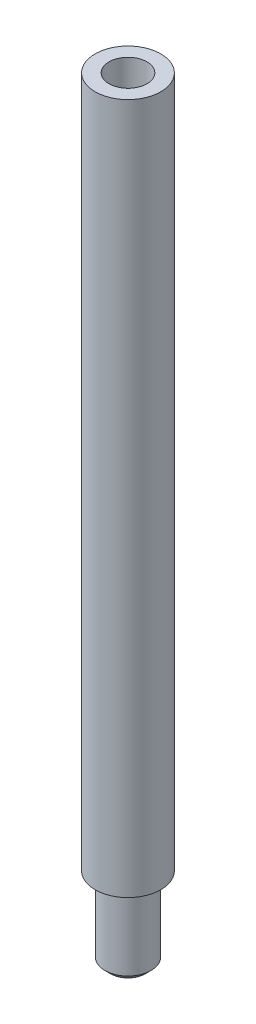
from build123d import *

# Parameters (mm, degrees)
SKETCH1_R                 = 2.85
BOSS_EXTRUDE1_DEPTH       = 60
SKETCH1_4_R               = 2
BOSS_EXTRUDE2_DEPTH       = 7
M4X0_7_TAPPED_HOLE1_D     = 3.3
M4X0_7_TAPPED_HOLE1_DEPTH = 10.1
M4X0_7_TAPPED_HOLE1_TIP   = 0.991420021
CHAMFER1_SIZE             = 0.5


with BuildPart() as part:
    # Sketch1 → Boss-Extrude1 (new body)
    with BuildSketch(Plane(origin=(0, 0, 0), x_dir=(1, 0, 0), z_dir=(0, 1, 0))):
        Circle(SKETCH1_R)
    extrude(amount=BOSS_EXTRUDE1_DEPTH)

    # Sketch1_4 → Boss-Extrude2 (add)
    with BuildSketch(Plane(origin=(0, 0, 0), x_dir=(1, 0, 0), z_dir=(0, 1, 0))):
        Circle(SKETCH1_4_R)
    extrude(amount=-BOSS_EXTRUDE2_DEPTH)

    # M4x0.7 Tapped Hole1
    with Locations(Plane(origin=(0, 60, 0), x_dir=(1, 0, 0), z_dir=(0, 1, 0))):
        with Locations((0, 0)):
            Hole(M4X0_7_TAPPED_HOLE1_D / 2, depth=M4X0_7_TAPPED_HOLE1_DEPTH)
            with Locations((0, 0, -(M4X0_7_TAPPED_HOLE1_DEPTH + M4X0_7_TAPPED_HOLE1_TIP / 2))):  # 118° drill point
                Cone(0, M4X0_7_TAPPED_HOLE1_D / 2, M4X0_7_TAPPED_HOLE1_TIP, mode=Mode.SUBTRACT)

    # Chamfer1
    chamfer1_edges = [part.edges().sort_by_distance(p)[0] for p in [
        (-2, -7, 0),
    ]]
    chamfer(chamfer1_edges, length=CHAMFER1_SIZE)


solid = part.part
